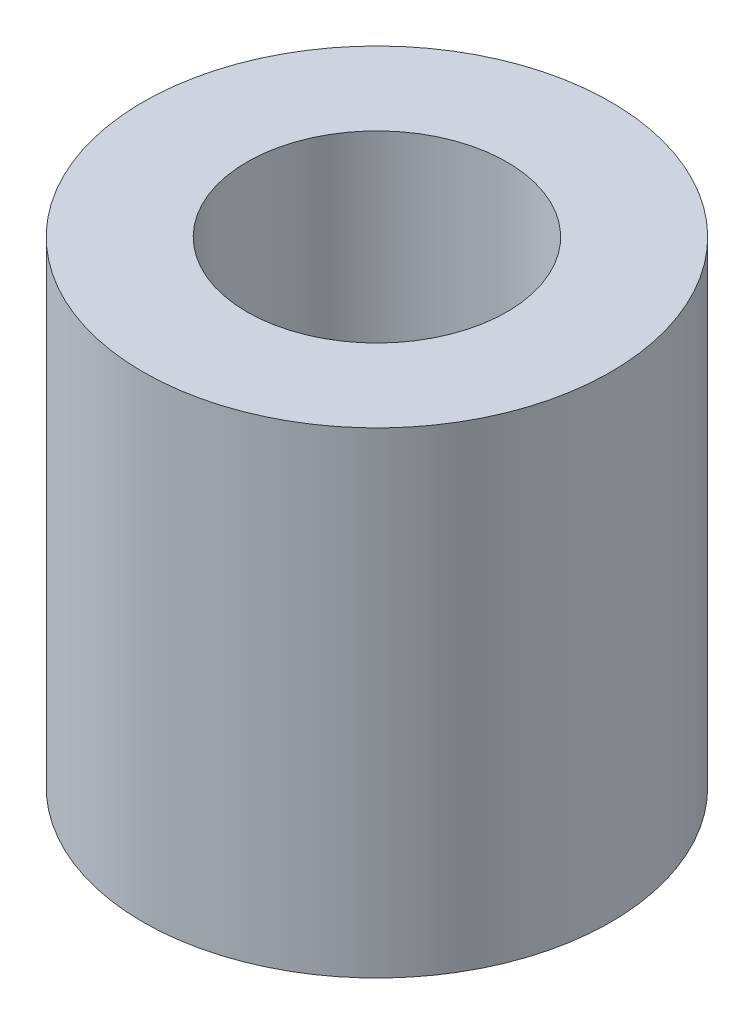
from build123d import *

# Parameters (mm, degrees)
SKETCH2_R           = 2.7
SKETCH2_R_2         = 1.5
BOSS_EXTRUDE1_DEPTH = 5.5


with BuildPart() as part:
    # Sketch2 → Boss-Extrude1 (new body)
    with BuildSketch(Plane(origin=(0, 0, 0), x_dir=(1, 0, 0), z_dir=(0, 1, 0))):
        Circle(SKETCH2_R)
        Circle(SKETCH2_R_2, mode=Mode.SUBTRACT)
    extrude(amount=BOSS_EXTRUDE1_DEPTH)


solid = part.part
